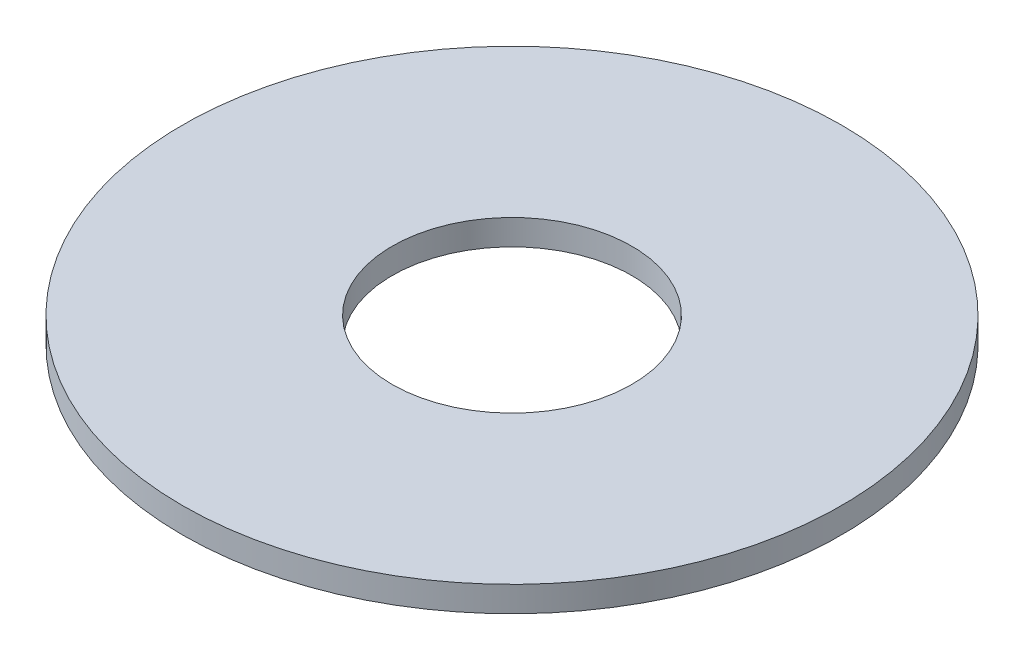
from build123d import *

# Parameters (mm, degrees)
SKETCH1_W = 7
SKETCH1_H = 0.85


with BuildPart() as part:
    # Sketch1 → Revolve1 (revolve)
    with BuildSketch(Plane(origin=(0, 0, 0), x_dir=(-1, 0, 0), z_dir=(0, 0, -1))):
        with Locations((-7.5, 0.425)):
            Rectangle(SKETCH1_W, SKETCH1_H)
    revolve(axis=Axis((0, 0, 0), (0, 1, 0)))


solid = part.part
